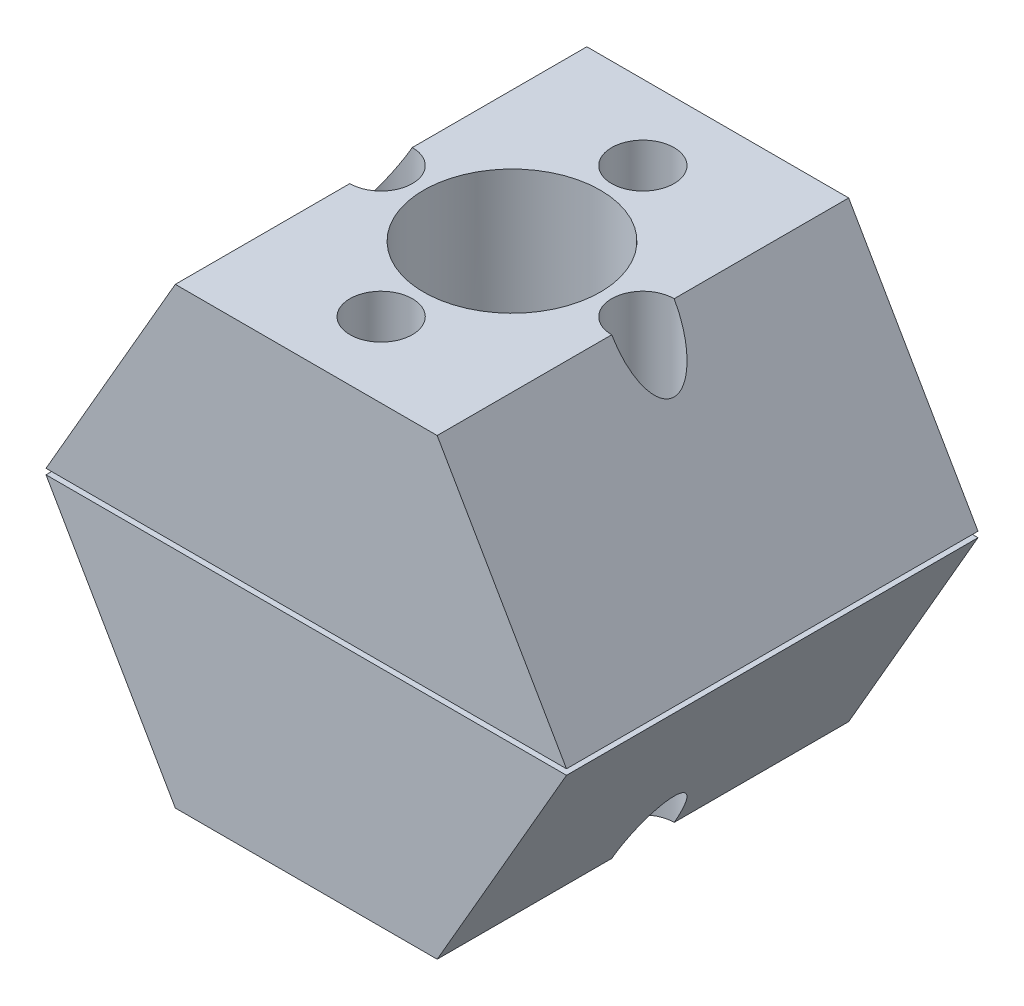
from build123d import *

# Parameters (mm, degrees)
SKETCH1_W                       = 27.94
SKETCH1_H                       = 15.7695
BOSS_EXTRUDE1_DEPTH             = 13.97
SKETCH1_H_2                     = 6.709500012
BOSS_EXTRUDE1_2_DEPTH           = 13.97
SKETCH4_R                       = 23.398189774
BODY_SHAPING_SQUARE_DEPTH       = 34.417
MAKING_THINGS_HEXAGONAL_DEPTH   = 27.94
SKETCH2_R                       = 6
THROUGH_HOLE_FOR_ACME_ROD_DEPTH = 31.795863359
SKETCH3_R                       = 0.85
BOLT_HOLES_DEPTH                = 1
BOLT_HOLES_DEPTH_BACK           = 31.795863359
SKETCH3_3_R                     = 2.12
CUT_EXTRUDE4_DEPTH              = 9.525
SKETCH5_R                       = 2.12
CUT_EXTRUDE5_DEPTH              = 9.525


with BuildPart() as part:
    # Sketch1 → Boss-Extrude1 (new body, symmetric)
    with BuildSketch(Plane.XY):
        with Locations((0, 11.42525)):
            Rectangle(SKETCH1_W, SKETCH1_H)
    extrude(amount=BOSS_EXTRUDE1_DEPTH, both=True)

    # Sketch1_6 → Cut-Revolve8 (revolve, cut)
    with BuildSketch(Plane.XY):
        Polygon((5.451, 15.881), (0, 15.881), (0, 3.5405), (11.381, 3.5405), (11.381, 5.581), (5.451, 5.581), align=None)
    revolve(axis=Axis((0, 19.31, 0), (0, -1, 0)), mode=Mode.SUBTRACT)


with BuildPart() as body_2:
    # Sketch1 → Boss-Extrude1 2 (new body, symmetric)
    with BuildSketch(Plane.XY):
        with Locations((0, -0.195250006)):
            Rectangle(SKETCH1_W, SKETCH1_H_2)
    extrude(amount=BOSS_EXTRUDE1_2_DEPTH, both=True)


with BuildPart() as body_shaping_square_tool:
    # Sketch4 → Body Shaping - Square (new body)
    with BuildSketch(Plane.XY.offset(13.97)):
        with Locations((0, 3.35)):
            Circle(SKETCH4_R)
        Polygon((-8.89, 18.747931679), (-17.78, 3.35), (-8.89, -12.047931679), (8.89, -12.047931679), (17.78, 3.35), (8.89, 18.747931679), align=None, mode=Mode.SUBTRACT)
    extrude(amount=-BODY_SHAPING_SQUARE_DEPTH)


with BuildPart() as part_1:
    add(part.part)

    # Body Shaping - Square: cut by body_shaping_square_tool
    add(body_shaping_square_tool.part, mode=Mode.SUBTRACT)



with BuildPart() as body_2_1:
    add(body_2.part)

    # Body Shaping - Square: cut by body_shaping_square_tool
    add(body_shaping_square_tool.part, mode=Mode.SUBTRACT)

    # Sketch1_7 → Cut-Revolve9 (revolve, cut)
    with BuildSketch(Plane.XY):
        Polygon((11.381, 3.1595), (0, 3.1595), (0, -0.381), (5.451, -0.381), (5.451, 1.119), (11.381, 1.119), align=None)
    revolve(axis=Axis((0, 15.881, 0), (0, -1, 0)), mode=Mode.SUBTRACT)


with BuildPart() as part_2:
    add(part_1.part)

    add(body_2_1.part)  # Making things hexagonal merges body 2
    # Sketch4_6 → Making things hexagonal (add)
    with BuildSketch(Plane.XY.offset(13.97)):
        Polygon((13.97, -3.249113577), (17.670014774, 3.1595), (13.97, 3.1595), align=None)
        Polygon((17.670014774, 3.5405), (13.97, 9.949113577), (13.97, 3.5405), align=None)
        Polygon((13.796283136, -3.550000012), (-13.796283136, -3.550000012), (-8.89, -12.047931679), (8.89, -12.047931679), align=None)
        Polygon((-13.97, 3.1595), (-17.670014774, 3.1595), (-13.97, -3.249113577), align=None)
        Polygon((-13.97, 3.5405), (-13.97, 9.949113577), (-17.670014774, 3.5405), align=None)
    extrude(amount=-MAKING_THINGS_HEXAGONAL_DEPTH)

    # Sketch2 → Through Hole for ACME Rod (cut, through all)
    with BuildSketch(Plane(origin=(0, -12.047931679, 0), x_dir=(1, 0, 0), z_dir=(0, 1, 0))):
        Circle(SKETCH2_R)
    extrude(amount=THROUGH_HOLE_FOR_ACME_ROD_DEPTH, mode=Mode.SUBTRACT)

    # Sketch3 → Bolt Holes (cut, two sides)
    with BuildSketch(Plane.XZ.offset(12.047931679)) as bolt_holes_sk:
        with Locations((-8.885, 0)):
            Circle(SKETCH3_R)
        with Locations((0, 8.885)):
            Circle(SKETCH3_R)
        with Locations((8.885, 0)):
            Circle(SKETCH3_R)
        with Locations((0, -8.885)):
            Circle(SKETCH3_R)
    extrude(amount=BOLT_HOLES_DEPTH, mode=Mode.SUBTRACT)
    extrude(bolt_holes_sk.sketch, amount=-BOLT_HOLES_DEPTH_BACK, mode=Mode.SUBTRACT)

    # Sketch3_3 → Cut-Extrude4 (cut)
    with BuildSketch(Plane.XZ.offset(12.047931679)):
        with Locations((-8.885, 0)):
            Circle(SKETCH3_3_R)
        with Locations((0, 8.885)):
            Circle(SKETCH3_3_R)
        with Locations((8.885, 0)):
            Circle(SKETCH3_3_R)
        with Locations((0, -8.885)):
            Circle(SKETCH3_3_R)
    extrude(amount=-CUT_EXTRUDE4_DEPTH, mode=Mode.SUBTRACT)

    # Sketch5 → Cut-Extrude5 (cut)
    with BuildSketch(Plane(origin=(0, 18.747931679, 0), x_dir=(1, 0, 0), z_dir=(0, 1, 0))):
        with Locations((0, 8.885)):
            Circle(SKETCH5_R)
        with Locations((-8.885, 0)):
            Circle(SKETCH5_R)
        with Locations((8.885, 0)):
            Circle(SKETCH5_R)
        with Locations((0, -8.885)):
            Circle(SKETCH5_R)
    extrude(amount=-CUT_EXTRUDE5_DEPTH, mode=Mode.SUBTRACT)


solid = part_2.part
